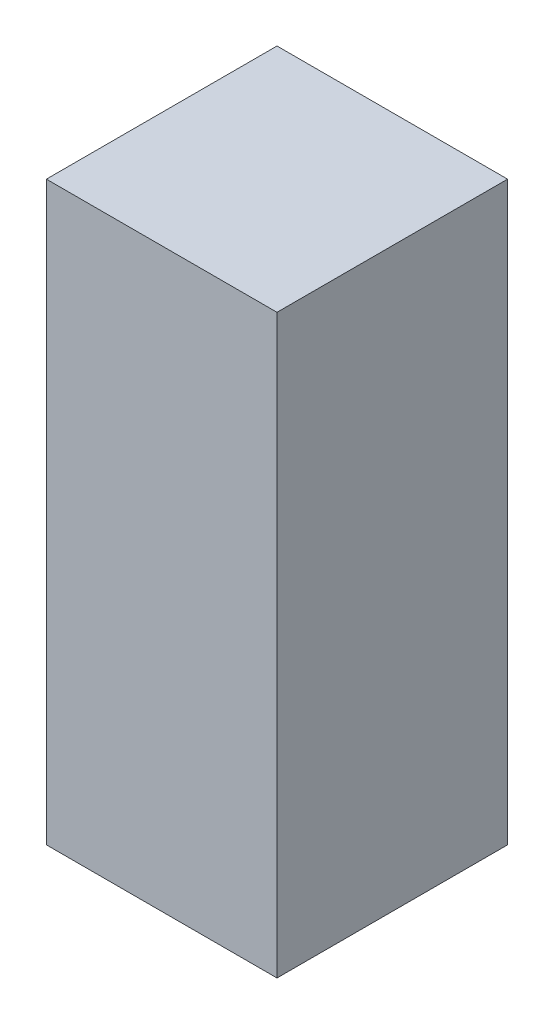
from build123d import *

# Parameters (mm, degrees)
SKETCH1_W           = 7.62
SKETCH1_H           = 7.62
BOSS_EXTRUDE1_DEPTH = 19.05
SKETCH2_W           = 6.032118198
SKETCH2_H           = 12.495149586
CUT_EXTRUDE1_DEPTH  = 8.62
SKETCH4_W           = 7.62
SKETCH4_H           = 19.05
BOSS_EXTRUDE3_DEPTH = 0.762


with BuildPart() as part:
    # Sketch1 → Boss-Extrude1 (new body)
    with BuildSketch(Plane(origin=(0, 0, 0), x_dir=(1, 0, 0), z_dir=(0, 1, 0))):
        Rectangle(SKETCH1_W, SKETCH1_H)
    extrude(amount=BOSS_EXTRUDE1_DEPTH)

    # Sketch2 → Cut-Extrude1 (cut, through all)
    with BuildSketch(Plane.XY.offset(3.81)):
        with Locations((0, 9.525)):
            Rectangle(SKETCH2_W, SKETCH2_H)
    extrude(amount=-CUT_EXTRUDE1_DEPTH, mode=Mode.SUBTRACT)

    # Sketch4 → Boss-Extrude3 (add)
    with BuildSketch(Plane.XY.offset(3.81)):
        with Locations((0, 9.525)):
            Rectangle(SKETCH4_W, SKETCH4_H)
    extrude(amount=-BOSS_EXTRUDE3_DEPTH)


solid = part.part
